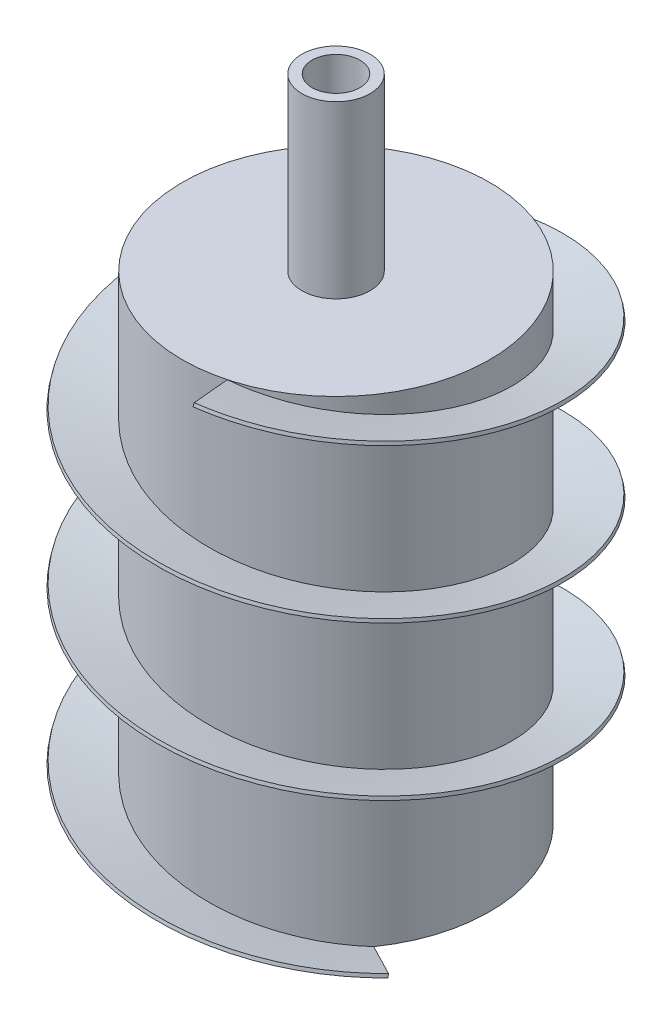
from build123d import *

# Parameters (mm, degrees)
SKETCH2_R               = 45
BOSS_EXTRUDE1_DEPTH     = 140
SWEEP2_PITCH            = 45
SWEEP2_HEIGHT           = 140
SWEEP2_RADIUS           = 45
SWEEP2_START_ANGLE      = 55
SKETCH7_W               = 15
SKETCH7_H               = 1
SKETCH9_R               = 3.9
SKETCH9_R_2             = 3.5
BOSS_EXTRUDE2_DEPTH     = 15
SKETCH10_R              = 10
SKETCH10_R_2            = 7
BOSS_EXTRUDE3_DEPTH     = 50
SKETCH19_R              = 42
CUT_EXTRUDE2_DEPTH      = 134
SKETCH20_R              = 1.5
CUT_EXTRUDE4_DEPTH      = 56.946827101
CUT_EXTRUDE4_DEPTH_BACK = 64.746830086


with BuildPart() as part:
    # Sketch2 → Boss-Extrude1 (new body)
    with BuildSketch(Plane(origin=(0, 0, 0), x_dir=(1, 0, 0), z_dir=(0, 1, 0))):
        Circle(SKETCH2_R)
    extrude(amount=BOSS_EXTRUDE1_DEPTH)

    # Sketch9 → Boss-Extrude2 (add)
    with BuildSketch(Plane(origin=(0, 0, 0), x_dir=(1, 0, 0), z_dir=(0, 1, 0))):
        Circle(SKETCH9_R)
        Circle(SKETCH9_R_2, mode=Mode.SUBTRACT)
    extrude(amount=-BOSS_EXTRUDE2_DEPTH)

    # Sketch10 → Boss-Extrude3 (add)
    with BuildSketch(Plane(origin=(0, 140, 0), x_dir=(1, 0, 0), z_dir=(0, 1, 0))):
        Circle(SKETCH10_R)
        Circle(SKETCH10_R_2, mode=Mode.SUBTRACT)
    extrude(amount=BOSS_EXTRUDE3_DEPTH)

    # Sketch19 → Cut-Extrude2 (cut)
    with BuildSketch(Plane(origin=(0, 137, 0), x_dir=(1, 0, 0), z_dir=(0, 1, 0))):
        Circle(SKETCH19_R)
    extrude(amount=-CUT_EXTRUDE2_DEPTH, mode=Mode.SUBTRACT)

    # Sketch20 → Cut-Extrude4 (cut, two sides)
    with BuildSketch(Plane.ZY.offset(3.9)) as cut_extrude4_sk:
        with Locations((0, -9)):
            Circle(SKETCH20_R)
    extrude(amount=CUT_EXTRUDE4_DEPTH, mode=Mode.SUBTRACT)
    extrude(cut_extrude4_sk.sketch, amount=-CUT_EXTRUDE4_DEPTH_BACK, mode=Mode.SUBTRACT)


with BuildPart() as body_2:
    # Sweep2: sweep along a helix
    with BuildLine() as sweep2_path:
        add(Helix(SWEEP2_PITCH, SWEEP2_HEIGHT, SWEEP2_RADIUS, center=(0, 0, 0), direction=(0, 1, 0), lefthand=True, mode=Mode.PRIVATE).rotate(Axis((0, 0, 0), (0, 1, 0)), SWEEP2_START_ANGLE))
    # Sketch7 → Sweep2 (sweep)
    with BuildSketch(Plane(origin=(11.64685703, 140, 43.466662183), x_dir=(-0.286143667, -0.220078885, -0.932570151), z_dir=(0.953919844, -0.157176725, -0.255602052))):
        with Locations((-7.5, -0.5)):
            Rectangle(SKETCH7_W, SKETCH7_H)
    sweep(path=sweep2_path.line, is_frenet=True)


solid = Compound([part.part, body_2.part])
